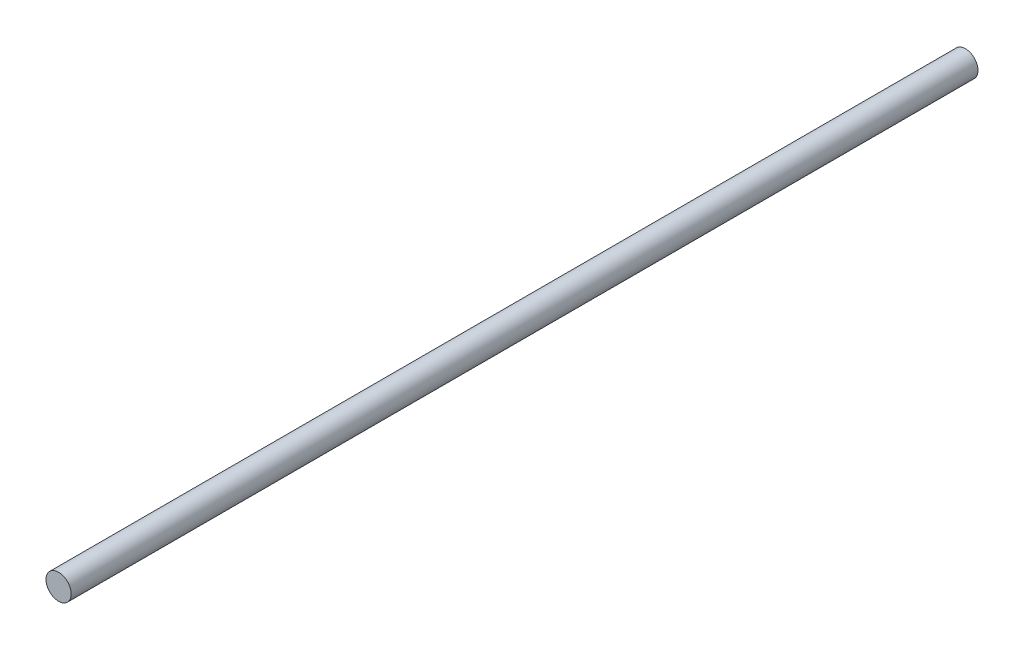
from build123d import *

# Parameters (mm, degrees)
SKETCH1_R           = 3.175
BOSS_EXTRUDE1_DEPTH = 114.3


with BuildPart() as part:
    # Sketch1 → Boss-Extrude1 (new body, symmetric)
    with BuildSketch(Plane.XY):
        Circle(SKETCH1_R)
    extrude(amount=BOSS_EXTRUDE1_DEPTH, both=True)


solid = part.part
